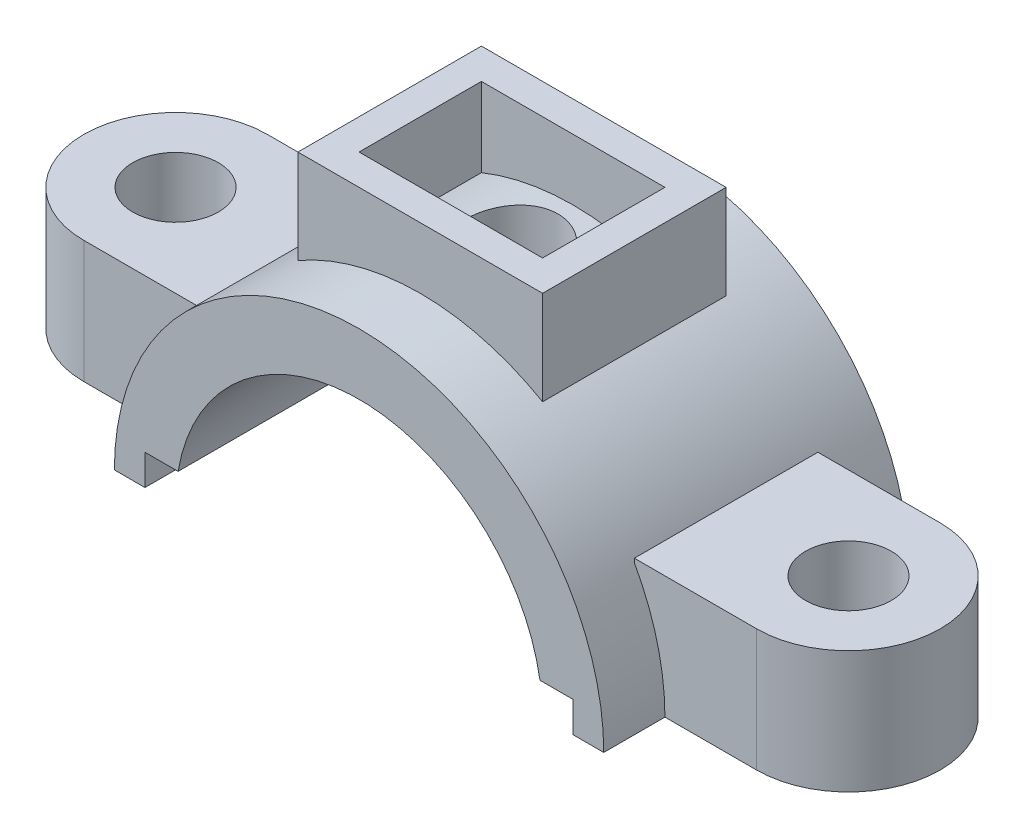
from build123d import *

# Parameters (mm, degrees)
SKETCH2_R                = 7
BOSS_EXTRUDE1_DEPTH      = 20
BOSS_EXTRUDE1_2_DEPTH    = 20
BOSS_EXTRUDE4_DEPTH      = 25
BOSS_EXTRUDE4_DEPTH_BACK = 25
BOSS_EXTRUDE5_REACH      = 52
SKETCH5_W                = 40
SKETCH5_H                = 30
SKETCH5_W_2              = 30
SKETCH5_H_2              = 20
SKETCH6_R                = 7.5
CUT_EXTRUDE1_DEPTH       = 51


with BuildPart() as part:
    # Sketch2 → Boss-Extrude1 (new body)
    with BuildSketch(Plane(origin=(0, 0, 0), x_dir=(1, 0, 0), z_dir=(0, 1, 0))):
        with BuildLine():
            Line((-55, 15), (-35, 15))
            Line((-35, 15), (-35, -15))
            Line((-35, -15), (-55, -15))
            ThreePointArc((-55, -15), (-70, 0), (-55, 15))
        make_face()
        with Locations((-55, 0)):
            Circle(SKETCH2_R, mode=Mode.SUBTRACT)
    extrude(amount=BOSS_EXTRUDE1_DEPTH)



with BuildPart() as body_2:
    # Sketch2 → Boss-Extrude1 2 (new body)
    with BuildSketch(Plane(origin=(0, 0, 0), x_dir=(1, 0, 0), z_dir=(0, 1, 0))):
        with BuildLine():
            Line((35, -15), (55, -15))
            ThreePointArc((55, -15), (70, 0), (55, 15))
            Line((55, 15), (35, 15))
            Line((35, 15), (35, -15))
        make_face()
        with Locations((55, 0)):
            Circle(SKETCH2_R, mode=Mode.SUBTRACT)
    extrude(amount=BOSS_EXTRUDE1_2_DEPTH)


with BuildPart() as part_1:
    add(part.part)

    add(body_2.part)  # Boss-Extrude4 merges body 2
    # Sketch3 → Boss-Extrude4 (add, two sides)
    with BuildSketch(Plane.XY) as boss_extrude4_sk:
        with BuildLine():
            ThreePointArc((29.580398915, 5), (0, 30), (-29.580398915, 5))
            Line((-29.580398915, 5), (-35, 5))
            Line((-35, 5), (-35, 0))
            Line((-35, 0), (-40, 0))
            ThreePointArc((-40, 0), (0, 40), (40, 0))
            Line((40, 0), (35, 0))
            Line((35, 0), (35, 5))
            Line((35, 5), (29.580398915, 5))
        make_face()
    extrude(amount=BOSS_EXTRUDE4_DEPTH)
    extrude(boss_extrude4_sk.sketch, amount=-BOSS_EXTRUDE4_DEPTH_BACK)

    # Sketch5 → Boss-Extrude5 (add, up to next)
    with BuildSketch(Plane(origin=(0, 50, 0), x_dir=(1, 0, 0), z_dir=(0, 1, 0)), mode=Mode.PRIVATE) as boss_extrude5_sk1:
        Rectangle(SKETCH5_W, SKETCH5_H)
        Rectangle(SKETCH5_W_2, SKETCH5_H_2, mode=Mode.SUBTRACT)
    boss_extrude5_tool1 = extrude(boss_extrude5_sk1.sketch, amount=-BOSS_EXTRUDE5_REACH, mode=Mode.PRIVATE) - part_1.part
    add(boss_extrude5_tool1.solids().sort_by_distance((0, 50, 14.5))[0])

    # Sketch6 → Cut-Extrude1 (cut, through all)
    with BuildSketch(Plane(origin=(0, 50, 0), x_dir=(1, 0, 0), z_dir=(0, 1, 0))):
        Circle(SKETCH6_R)
    extrude(amount=-CUT_EXTRUDE1_DEPTH, mode=Mode.SUBTRACT)


solid = part_1.part
